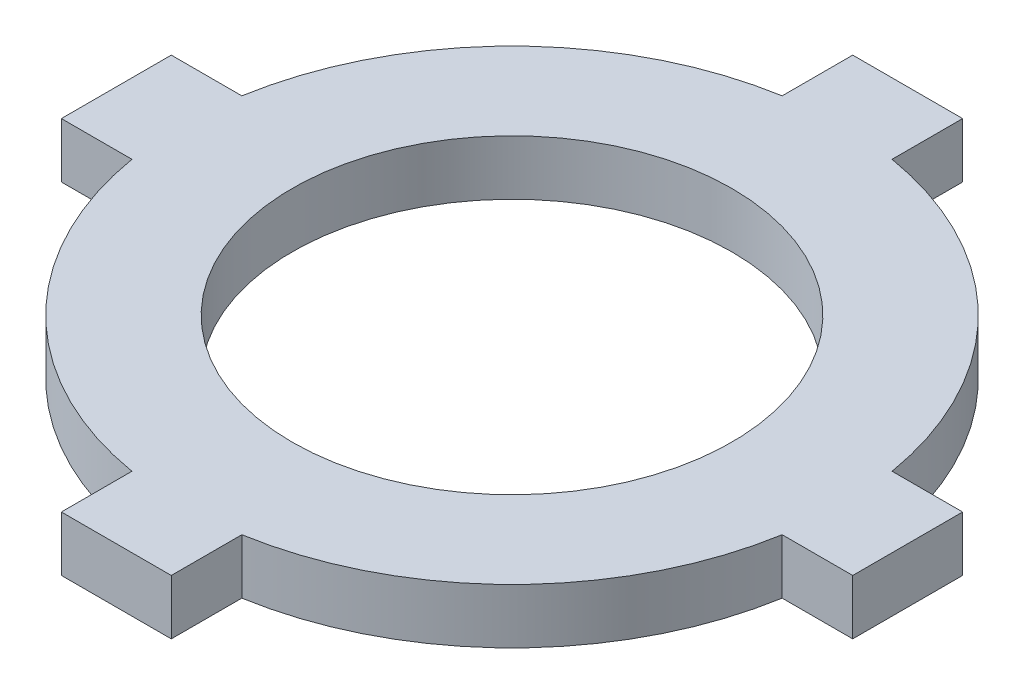
from build123d import *

# Parameters (mm, degrees)
SKETCH1_R           = 12.7
BOSS_EXTRUDE1_DEPTH = 3.175


with BuildPart() as part:
    # Sketch1 → Boss-Extrude1 (new body)
    with BuildSketch(Plane(origin=(0, 0, 0), x_dir=(1, 0, 0), z_dir=(0, 1, 0))):
        with BuildLine():
            Line((-18.783553311, -3.175), (-22.86, -3.175))
            Line((-22.86, -3.175), (-22.86, 3.175))
            Line((-22.86, 3.175), (-18.783553311, 3.175))
            ThreePointArc((-18.783553311, 3.175), (-13.470384182, 13.470384182), (-3.175, 18.783553311))
            Line((-3.175, 18.783553311), (-3.175, 22.86))
            Line((-3.175, 22.86), (3.175, 22.86))
            Line((3.175, 22.86), (3.175, 18.783553311))
            ThreePointArc((3.175, 18.783553311), (13.470384182, 13.470384182), (18.783553311, 3.175))
            Line((18.783553311, 3.175), (22.86, 3.175))
            Line((22.86, 3.175), (22.86, -3.175))
            Line((22.86, -3.175), (18.783553311, -3.175))
            ThreePointArc((18.783553311, -3.175), (13.470384182, -13.470384182), (3.175, -18.783553311))
            Line((3.175, -18.783553311), (3.175, -22.86))
            Line((3.175, -22.86), (-3.175, -22.86))
            Line((-3.175, -22.86), (-3.175, -18.783553311))
            ThreePointArc((-3.175, -18.783553311), (-13.470384182, -13.470384182), (-18.783553311, -3.175))
        make_face()
        Circle(SKETCH1_R, mode=Mode.SUBTRACT)
    extrude(amount=BOSS_EXTRUDE1_DEPTH)


solid = part.part
